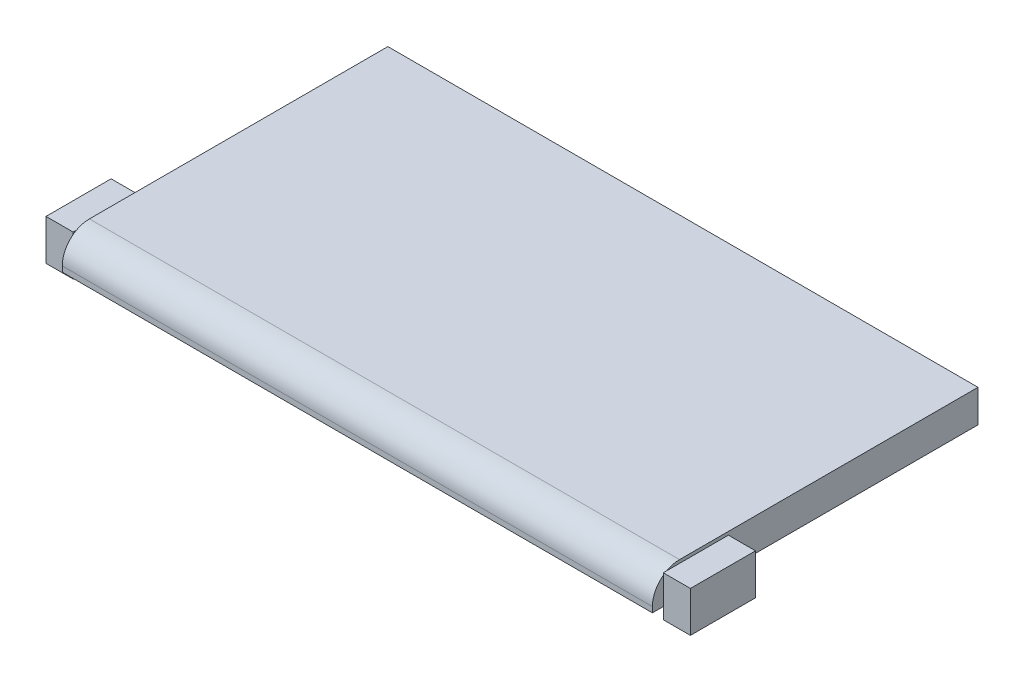
from build123d import *

# Parameters (mm, degrees)
SKETCH1_W                            = 276.225
SKETCH1_H                            = 152.4
SKETCH1_W_2                          = 273.177
SKETCH1_H_2                          = 149.352
BULK_EXTRUDE_DEPTH                   = 15.24
FILLET1_R                            = 12.7
SHELL_T                              = -1.524
SKETCH2_R                            = 1.651
BOSS_EXTRUDE3_DEPTH                  = 50.8
SKETCH3_W                            = 30.48
SKETCH3_H                            = 19.05
LATCH_CLEAR_HOOK_RIGHT_EXTRUDE_DEPTH = 12.7


with BuildPart() as part:
    # Sketch1 → Bulk-Extrude (new body)
    with BuildSketch(Plane(origin=(0, 0, 0), x_dir=(1, 0, 0), z_dir=(0, 1, 0))):
        with Locations((136.5885, 74.676)):
            Rectangle(SKETCH1_W, SKETCH1_H)
        with Locations((136.5885, 74.676)):
            Rectangle(SKETCH1_W_2, SKETCH1_H_2, mode=Mode.SUBTRACT)
        with Locations((136.5885, 74.676)):
            Rectangle(SKETCH1_W_2, SKETCH1_H_2)
    extrude(amount=BULK_EXTRUDE_DEPTH)

    # Fillet1
    fillet1_edges = [part.edges().sort_by_distance(p)[0] for p in [
        (136.5885, 15.24, 1.524),
    ]]
    fillet(fillet1_edges, radius=FILLET1_R)

    # Shell
    shell_openings = [part.faces().sort_by_distance(p)[0] for p in [
        (136.5885, 0, -74.676),
    ]]
    offset(amount=SHELL_T, openings=shell_openings, kind=Kind.INTERSECTION)

    # Sketch2 → Boss-Extrude3 (add, symmetric)
    with BuildSketch(Plane(origin=(136.5885, 0, 0), x_dir=(0, 0, -1), z_dir=(1, 0, 0))):
        with BuildLine():
            Line((150.876, 3.175), (150.876, 0))
            ThreePointArc((150.876, 0), (156.29606403, -2.24506403), (154.051, 3.175))
            Line((154.051, 3.175), (150.876, 3.175))
        make_face()
        with Locations((154.051, 0)):
            Circle(SKETCH2_R, mode=Mode.SUBTRACT)
    extrude(amount=BOSS_EXTRUDE3_DEPTH, both=True)


with BuildPart() as body_2:
    # Sketch3 → Latch Clear. Hook, Right-Extrude (new body)
    with BuildSketch(Plane(origin=(274.701, 0, 0), x_dir=(0, 0, -1), z_dir=(1, 0, 0))):
        with Locations((18.796, 4.191)):
            Rectangle(SKETCH3_W, SKETCH3_H)
    latch_clear_hook_right_extrude = extrude(amount=LATCH_CLEAR_HOOK_RIGHT_EXTRUDE_DEPTH)


with BuildPart() as part_1:
    add(part.part)

    # Latch Clear. Hook, Left-Mirror: Latch Clear. Hook, Right-Extrude across plane
    add(latch_clear_hook_right_extrude.mirror(Plane(origin=(136.5885, 0, 0), x_dir=(0, 0, 1), z_dir=(1, 0, 0))))


solid = Compound([body_2.part, part_1.part])
